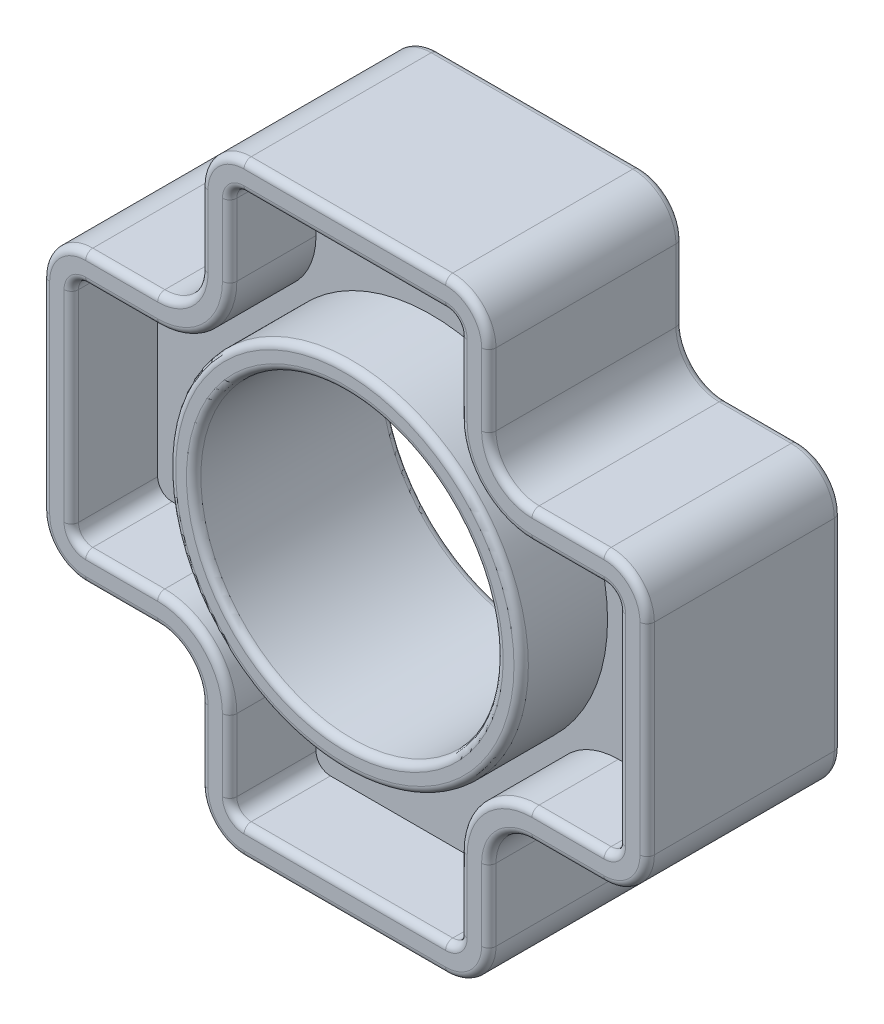
from build123d import *

# Parameters (mm, degrees)
EXTRUDE_1_DEPTH     = 13.5
FILLET_1_R          = 3
CUT_EXTRUDE_1_DEPTH = 6
CUT_EXTRUDE_2_DEPTH = 6
EXTRUDE_START       = -7.5
SKETCH_4_R          = 12.25
EXTRUDE_3_DEPTH     = 13.5
CUT_EXTRUDE_3_REACH = 15.5
SKETCH_5_R          = 10.5
FILLET_2_R          = 0.5


with BuildPart() as part:
    # 草圖1 → 填料-伸長1 (new body)
    with BuildSketch(Plane.XY):
        Polygon((-10, 21), (-10, 10), (-21, 10), (-21, -10), (-10, -10), (-10, -21), (10, -21), (10, -10), (21, -10), (21, 10), (10, 10), (10, 21), align=None)
    extrude(amount=EXTRUDE_1_DEPTH)

    # 圓角1
    fillet_1_edges = [part.edges().sort_by_distance(p)[0] for p in [
        (10, 21, 6.75),
        (10, 10, 6.75),
        (21, 10, 6.75),
        (21, -10, 6.75),
        (10, -10, 6.75),
        (10, -21, 6.75),
        (-10, -21, 6.75),
        (-10, -10, 6.75),
        (-21, -10, 6.75),
        (-21, 10, 6.75),
        (-10, 10, 6.75),
        (-10, 21, 6.75),
    ]]
    fillet(fillet_1_edges, radius=FILLET_1_R)

    # 草圖2 → 除料-伸長1 (cut)
    with BuildSketch(Plane.XY.offset(13.5)):
        with BuildLine():
            Line((-13, 8), (-18, 8))
            ThreePointArc((-18, 8), (-18.707106781, 7.707106781), (-19, 7))
            Line((-19, 7), (-19, -7))
            ThreePointArc((-19, -7), (-18.707106781, -7.707106781), (-18, -8))
            Line((-18, -8), (-13, -8))
            ThreePointArc((-13, -8), (-9.464466094, -9.464466094), (-8, -13))
            Line((-8, -13), (-8, -18))
            ThreePointArc((-8, -18), (-7.707106781, -18.707106781), (-7, -19))
            Line((-7, -19), (7, -19))
            ThreePointArc((7, -19), (7.707106781, -18.707106781), (8, -18))
            Line((8, -18), (8, -13))
            ThreePointArc((8, -13), (9.464466094, -9.464466094), (13, -8))
            Line((13, -8), (18, -8))
            ThreePointArc((18, -8), (18.707106781, -7.707106781), (19, -7))
            Line((19, -7), (19, 7))
            ThreePointArc((19, 7), (18.707106781, 7.707106781), (18, 8))
            Line((18, 8), (13, 8))
            ThreePointArc((13, 8), (9.464466094, 9.464466094), (8, 13))
            Line((8, 13), (8, 18))
            ThreePointArc((8, 18), (7.707106781, 18.707106781), (7, 19))
            Line((7, 19), (-7, 19))
            ThreePointArc((-7, 19), (-7.707106781, 18.707106781), (-8, 18))
            Line((-8, 18), (-8, 13))
            ThreePointArc((-8, 13), (-9.464466094, 9.464466094), (-13, 8))
        make_face()
    extrude(amount=-CUT_EXTRUDE_1_DEPTH, mode=Mode.SUBTRACT)

    # 草圖3 → 除料-伸長2 (cut)
    with BuildSketch(Plane(origin=(0, 0, 0), x_dir=(-1, 0, 0), z_dir=(0, 0, -1))):
        with BuildLine():
            Line((19, -7), (19, 7))
            ThreePointArc((19, 7), (18.707106781, 7.707106781), (18, 8))
            Line((18, 8), (13, 8))
            ThreePointArc((13, 8), (9.464466094, 9.464466094), (8, 13))
            Line((8, 13), (8, 18))
            ThreePointArc((8, 18), (7.707106781, 18.707106781), (7, 19))
            Line((7, 19), (-7, 19))
            ThreePointArc((-7, 19), (-7.707106781, 18.707106781), (-8, 18))
            Line((-8, 18), (-8, 13))
            ThreePointArc((-8, 13), (-9.464466094, 9.464466094), (-13, 8))
            Line((-13, 8), (-18, 8))
            ThreePointArc((-18, 8), (-18.707106781, 7.707106781), (-19, 7))
            Line((-19, 7), (-19, -7))
            ThreePointArc((-19, -7), (-18.707106781, -7.707106781), (-18, -8))
            Line((-18, -8), (-13, -8))
            ThreePointArc((-13, -8), (-9.464466094, -9.464466094), (-8, -13))
            Line((-8, -13), (-8, -18))
            ThreePointArc((-8, -18), (-7.707106781, -18.707106781), (-7, -19))
            Line((-7, -19), (7, -19))
            ThreePointArc((7, -19), (7.707106781, -18.707106781), (8, -18))
            Line((8, -18), (8, -13))
            ThreePointArc((8, -13), (9.464466094, -9.464466094), (13, -8))
            Line((13, -8), (18, -8))
            ThreePointArc((18, -8), (18.707106781, -7.707106781), (19, -7))
        make_face()
    extrude(amount=-CUT_EXTRUDE_2_DEPTH, mode=Mode.SUBTRACT)

    # 草圖4 → 填料-伸長3 (add)
    with BuildSketch(Plane(origin=(0, 0, 6), x_dir=(-1, 0, 0), z_dir=(0, 0, -1)).offset(EXTRUDE_START)):
        Circle(SKETCH_4_R)
    extrude(amount=EXTRUDE_3_DEPTH)

    # 草圖5 → 除料-伸長3 (cut, up to next)
    with BuildSketch(Plane.XY.offset(13.5), mode=Mode.PRIVATE) as cut_extrude_3_sk1:
        Circle(SKETCH_5_R)
    cut_extrude_3_tool1 = extrude(cut_extrude_3_sk1.sketch, amount=-CUT_EXTRUDE_3_REACH, mode=Mode.PRIVATE) & part.part
    add(cut_extrude_3_tool1.solids().sort_by_distance((0, 0, 13.5))[0], mode=Mode.SUBTRACT)

    # 圓角2
    fillet_2_edges = [part.edges().sort_by_distance(p)[0] for p in [
        (-9.464466094, 9.464466094, 13.5),
        (-15.5, 8, 13.5),
        (-18.707106781, 7.707106781, 13.5),
        (-19, 0, 13.5),
        (-18.707106781, -7.707106781, 13.5),
        (-15.5, -8, 13.5),
        (-9.464466094, -9.464466094, 13.5),
        (-8, -15.5, 13.5),
        (-7.707106781, -18.707106781, 13.5),
        (0, -19, 13.5),
        (7.707106781, -18.707106781, 13.5),
        (8, -15.5, 13.5),
        (9.464466094, -9.464466094, 13.5),
        (15.5, -8, 13.5),
        (18.707106781, -7.707106781, 13.5),
        (19, 0, 13.5),
        (18.707106781, 7.707106781, 13.5),
        (15.5, 8, 13.5),
        (9.464466094, 9.464466094, 13.5),
        (8, 15.5, 13.5),
        (7.707106781, 18.707106781, 13.5),
        (0, 19, 13.5),
        (-7.707106781, 18.707106781, 13.5),
        (-8, 15.5, 13.5),
        (-18.707106781, -7.707106781, 0),
        (-19, 0, 0),
        (-18.707106781, 7.707106781, 0),
        (-15.5, 8, 0),
        (-9.464466094, 9.464466094, 0),
        (-8, 15.5, 0),
        (-7.707106781, 18.707106781, 0),
        (0, 19, 0),
        (7.707106781, 18.707106781, 0),
        (8, 15.5, 0),
        (9.464466094, 9.464466094, 0),
        (15.5, 8, 0),
        (18.707106781, 7.707106781, 0),
        (19, 0, 0),
        (18.707106781, -7.707106781, 0),
        (15.5, -8, 0),
        (9.464466094, -9.464466094, 0),
        (8, -15.5, 0),
        (7.707106781, -18.707106781, 0),
        (0, -19, 0),
        (-7.707106781, -18.707106781, 0),
        (-8, -15.5, 0),
        (-9.464466094, -9.464466094, 0),
        (-15.5, -8, 0),
        (12.25, 0, 13.5),
        (12.25, 0, 0),
        (-10.5, 0, 13.5),
        (-10.5, 0, 0),
        (-15.5, 10, 0),
        (-15.5, 10, 13.5),
        (-10, 15.5, 0),
        (-10, 15.5, 13.5),
        (-21, 0, 0),
        (-21, 0, 13.5),
        (0, 21, 0),
        (10, 15.5, 0),
        (15.5, 10, 0),
        (21, 0, 0),
        (15.5, -10, 0),
        (10, -15.5, 0),
        (0, -21, 0),
        (-10, -15.5, 0),
        (-15.5, -10, 0),
        (-9.121320344, 20.121320344, 0),
        (9.121320344, 20.121320344, 0),
        (20.121320344, 9.121320344, 0),
        (20.121320344, -9.121320344, 0),
        (9.121320344, -20.121320344, 0),
        (-9.121320344, -20.121320344, 0),
        (-20.121320344, -9.121320344, 0),
        (-20.121320344, 9.121320344, 0),
        (0, 21, 13.5),
        (-15.5, -10, 13.5),
        (-10, -15.5, 13.5),
        (0, -21, 13.5),
        (10, -15.5, 13.5),
        (15.5, -10, 13.5),
        (21, 0, 13.5),
        (15.5, 10, 13.5),
        (10, 15.5, 13.5),
        (-9.121320344, 20.121320344, 13.5),
        (9.121320344, 20.121320344, 13.5),
        (20.121320344, 9.121320344, 13.5),
        (20.121320344, -9.121320344, 13.5),
        (9.121320344, -20.121320344, 13.5),
        (-9.121320344, -20.121320344, 13.5),
        (-20.121320344, -9.121320344, 13.5),
        (-20.121320344, 9.121320344, 13.5),
        (-10.878679656, 10.878679656, 0),
        (-10.878679656, 10.878679656, 13.5),
        (-10.878679656, -10.878679656, 0),
        (-10.878679656, -10.878679656, 13.5),
        (10.878679656, -10.878679656, 0),
        (10.878679656, -10.878679656, 13.5),
        (10.878679656, 10.878679656, 0),
        (10.878679656, 10.878679656, 13.5),
    ]]
    fillet(fillet_2_edges, radius=FILLET_2_R)


solid = part.part
